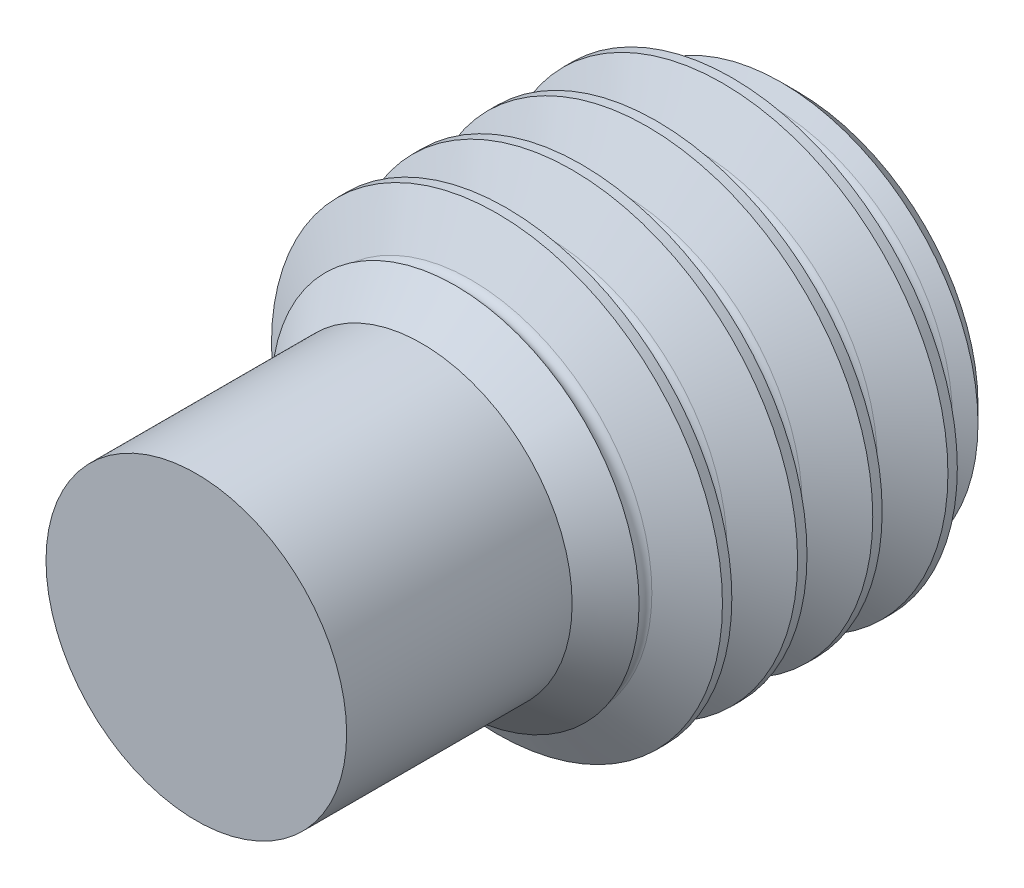
from build123d import *

# Parameters (mm, degrees)
SKETCH5_W           = 4
SKETCH5_H           = 1.5
THREAD_SIMPLE_COUNT = 9
THREAD_SIMPLE_PITCH = 0.5
CUT_HEAD_KEY_DEPTH  = 1.5


with BuildPart() as part:
    # Sketch5 → body (revolve)
    with BuildSketch(Plane(origin=(0, 0, 0), x_dir=(0, 0, -1), z_dir=(1, 0, 0))):
        with Locations((-2, 0.75)):
            Rectangle(SKETCH5_W, SKETCH5_H)
    revolve(axis=Axis((0, 0, 4), (0, 0, -1)))

    # Sketch13 → cut-chamfer-end (revolve, cut)
    with BuildSketch(Plane(origin=(0, 0, 0), x_dir=(0, 0, -1), z_dir=(1, 0, 0))):
        Polygon((0, -1.5), (-0.3, -1.5), (0, -1.2), align=None)
    revolve(axis=Axis((0, 0, 4), (0, 0, -1)), mode=Mode.SUBTRACT)

    # Sketch8 → thread-single (revolve, cut)
    with BuildSketch(Plane(origin=(0, 0, 0), x_dir=(0, 0, -1), z_dir=(1, 0, 0))):
        with BuildLine():
            Line((-0.4375, -1.5), (0, -1.5))
            Line((0, -1.5), (-0.171875, -1.202303767))
            ThreePointArc((-0.171875, -1.202303767), (-0.21875, -1.175240474), (-0.265625, -1.202303767))
            Line((-0.265625, -1.202303767), (-0.4375, -1.5))
        make_face()
    thread_single = revolve(axis=Axis((0, 0, 4), (0, 0, -1)), mode=Mode.SUBTRACT)

    # thread-simple: thread-single ×9
    with Locations(*[(0, 0, i * THREAD_SIMPLE_PITCH) for i in range(1, THREAD_SIMPLE_COUNT)]):
        add(thread_single, mode=Mode.SUBTRACT)

    # Sketch25 → cut-head-key (cut)
    with BuildSketch(Plane.XY):
        Polygon((0.433012702, 0.75), (-0.433012702, 0.75), (-0.866025404, 0), (-0.433012702, -0.75), (0.433012702, -0.75), (0.866025404, 0), align=None)
    extrude(amount=CUT_HEAD_KEY_DEPTH, mode=Mode.SUBTRACT)

    # Sketch26 → cut-top-body (revolve, cut)
    with BuildSketch(Plane(origin=(0, 0, 0), x_dir=(0, 0, -1), z_dir=(1, 0, 0))):
        Polygon((-4, -1.5), (-4, -1), (-2.5, -1), (-2, -1.5), align=None)
    revolve(axis=Axis((0, 0, 4), (0, 0, -1)), mode=Mode.SUBTRACT)


solid = part.part
